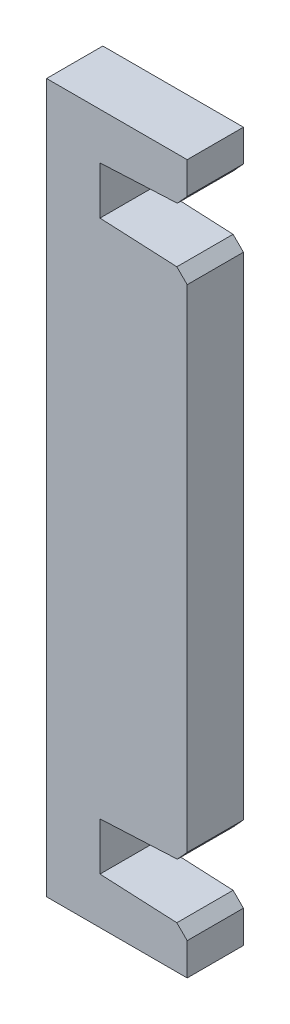
from build123d import *
from OCP.BRepFilletAPI import BRepFilletAPI_MakeChamfer

# Parameters (mm, degrees)
BOSS_EXTRUDE1_DEPTH = 4
CHAMFER1_SIZE       = 0.7
CHAMFER1_SIZE2      = 0.736453843


with BuildPart() as part:
    # Sketch1 → Boss-Extrude1 (new body)
    with BuildSketch(Plane.XY):
        Polygon((-10, 0), (0, 0), (0, 18.2), (-6.2, 18.5), (-6.2, 21.9), (0, 22.2), (0, 25.2), (-10, 25.2), align=None)
        Polygon((-6.2, -18.5), (0, -18.2), (0, 0), (-10, 0), (-10, -25.2), (0, -25.2), (0, -22.2), (-6.2, -21.9), align=None)
    extrude(amount=BOSS_EXTRUDE1_DEPTH)

    # Chamfer1: one chamfer whose edges measure the first distance from different faces: ONE call of the kernel's chamfer builder (chamfer() names one face for all edges)
    chamfer1_edges_1 = [part.edges().sort_by_distance(p)[0] for p in [
        (0, 22.2, 2),
    ]]
    chamfer1_side_1 = [part.faces().sort_by_distance(p)[0] for p in [
        (-3.1, 22.05, 2),
    ]]
    chamfer1_edges_2 = [part.edges().sort_by_distance(p)[0] for p in [
        (0, 18.2, 2),
    ]]
    chamfer1_side_2 = [part.faces().sort_by_distance(p)[0] for p in [
        (0, 0, 2),
    ]]
    chamfer1_edges_3 = [part.edges().sort_by_distance(p)[0] for p in [
        (0, -18.2, 2),
    ]]
    chamfer1_side_3 = [part.faces().sort_by_distance(p)[0] for p in [
        (-3.1, -18.35, 2),
    ]]
    chamfer1_edges_4 = [part.edges().sort_by_distance(p)[0] for p in [
        (0, -22.2, 2),
    ]]
    chamfer1_side_4 = [part.faces().sort_by_distance(p)[0] for p in [
        (0, -23.7, 2),
    ]]
    chamfer1 = BRepFilletAPI_MakeChamfer(part.part.solid().wrapped)
    for e in chamfer1_edges_1:
        chamfer1.Add(CHAMFER1_SIZE, CHAMFER1_SIZE2, e.wrapped, chamfer1_side_1[0].wrapped)  # the first distance lies on this face
    for e in chamfer1_edges_2:
        chamfer1.Add(CHAMFER1_SIZE, CHAMFER1_SIZE2, e.wrapped, chamfer1_side_2[0].wrapped)  # the first distance lies on this face
    for e in chamfer1_edges_3:
        chamfer1.Add(CHAMFER1_SIZE, CHAMFER1_SIZE2, e.wrapped, chamfer1_side_3[0].wrapped)  # the first distance lies on this face
    for e in chamfer1_edges_4:
        chamfer1.Add(CHAMFER1_SIZE, CHAMFER1_SIZE2, e.wrapped, chamfer1_side_4[0].wrapped)  # the first distance lies on this face
    add(Compound.cast(chamfer1.Shape()), mode=Mode.REPLACE)


solid = part.part
